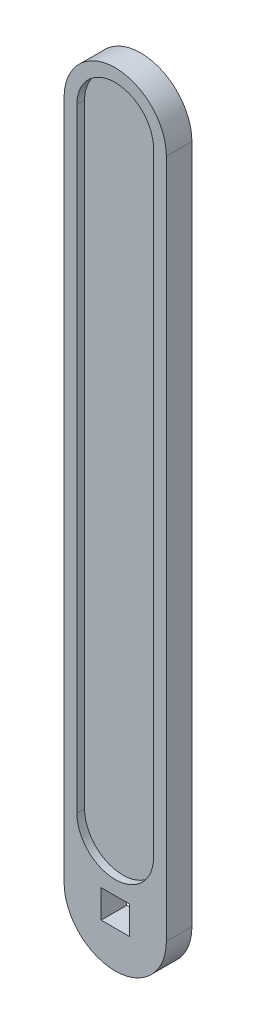
from build123d import *

# Parameters (mm, degrees)
EXTRUDE_1_DEPTH = 1
SKETCH_2_W      = 5.5
SKETCH_2_H      = 5.5
EXTRUDE_2_DEPTH = 2.5


with BuildPart() as part:
    # 草图1 → 凸台-拉伸1 (new body, symmetric)
    with BuildSketch(Plane.XY):
        with BuildLine():
            Line((-7.5, 0), (-7.5, 120))
            ThreePointArc((-7.5, 120), (0, 127.5), (7.5, 120))
            Line((7.5, 120), (7.5, 0))
            ThreePointArc((7.5, 0), (0, -7.5), (-7.5, 0))
        make_face()
    extrude(amount=EXTRUDE_1_DEPTH, both=True)

    # 草图2 → 凸台-拉伸2 (add, symmetric)
    with BuildSketch(Plane.XY):
        with BuildLine():
            Line((-10, 0), (-10, -13))
            ThreePointArc((-10, -13), (0, -23), (10, -13))
            Line((10, -13), (10, 0))
            Line((10, 0), (10, 120))
            ThreePointArc((10, 120), (0, 130), (-10, 120))
            Line((-10, 120), (-10, 0))
        make_face()
        with Locations((0, -13)):
            Rectangle(SKETCH_2_W, SKETCH_2_H, mode=Mode.SUBTRACT)
        with BuildLine():
            Line((-7.5, 120), (-7.5, 0))
            ThreePointArc((-7.5, 0), (0, -7.5), (7.5, 0))
            Line((7.5, 0), (7.5, 120))
            ThreePointArc((7.5, 120), (0, 127.5), (-7.5, 120))
        make_face(mode=Mode.SUBTRACT)
    extrude(amount=EXTRUDE_2_DEPTH, both=True)


solid = part.part
